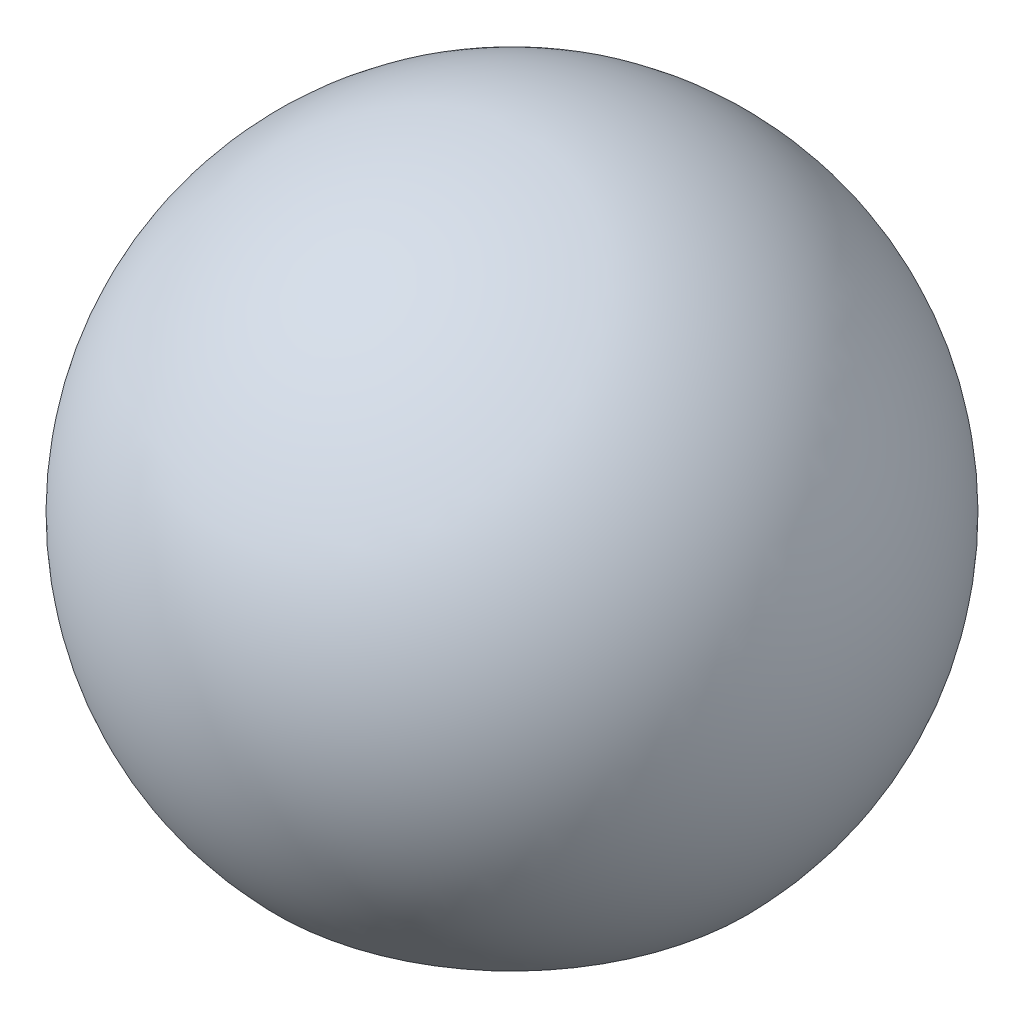
from build123d import *


with BuildPart() as part:
    # Sketch1 → Revolve2 (revolve)
    with BuildSketch(Plane.XY):
        with BuildLine():
            Line((2.5, -2.449489743), (0, -2.449489743))
            Line((0, -2.449489743), (0, 3.5))
            ThreePointArc((0, 3.5), (3.226702194, 1.355873501), (2.5, -2.449489743))
        make_face()
    revolve(axis=Axis((0, -2.449489743, 0), (0, 1, 0)))


solid = part.part
